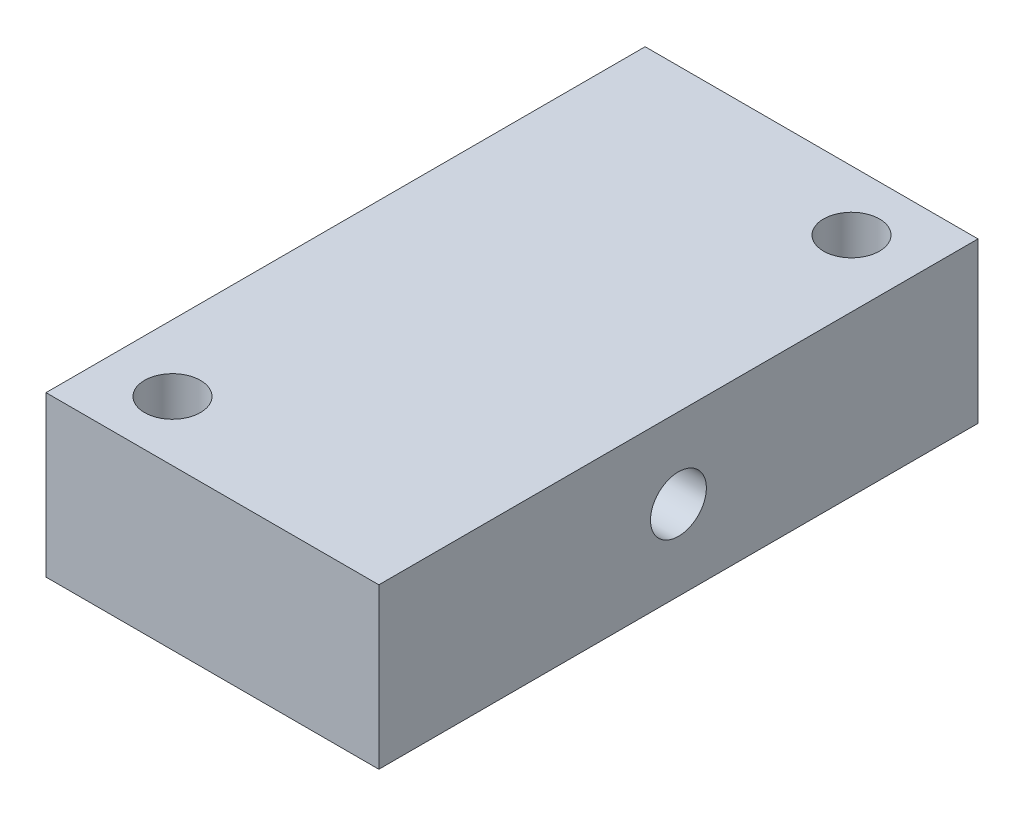
from build123d import *

# Parameters (mm, degrees)
SKETCH1_W           = 25
SKETCH1_H           = 45
BOSS_EXTRUDE1_DEPTH = 12
M5_TAPPED_HOLE1_D   = 4.2
M5_TAPPED_HOLE2_D   = 4.2


with BuildPart() as part:
    # Sketch1 → Boss-Extrude1 (new body)
    with BuildSketch(Plane(origin=(0, 0, 0), x_dir=(1, 0, 0), z_dir=(0, 1, 0))):
        Rectangle(SKETCH1_W, SKETCH1_H)
    extrude(amount=BOSS_EXTRUDE1_DEPTH)

    # M5 Tapped Hole1 (through all)
    with Locations(Plane(origin=(0, 12, 0), x_dir=(1, 0, 0), z_dir=(0, 1, 0))):
        with Locations((7.5, 18), (-7.5, -18)):
            Hole(M5_TAPPED_HOLE1_D / 2)

    # M5 Tapped Hole2 (through all)
    with Locations(Plane(origin=(12.5, 0, 0), x_dir=(0, 0, -1), z_dir=(1, 0, 0))):
        with Locations((0, 6)):
            Hole(M5_TAPPED_HOLE2_D / 2)


solid = part.part
